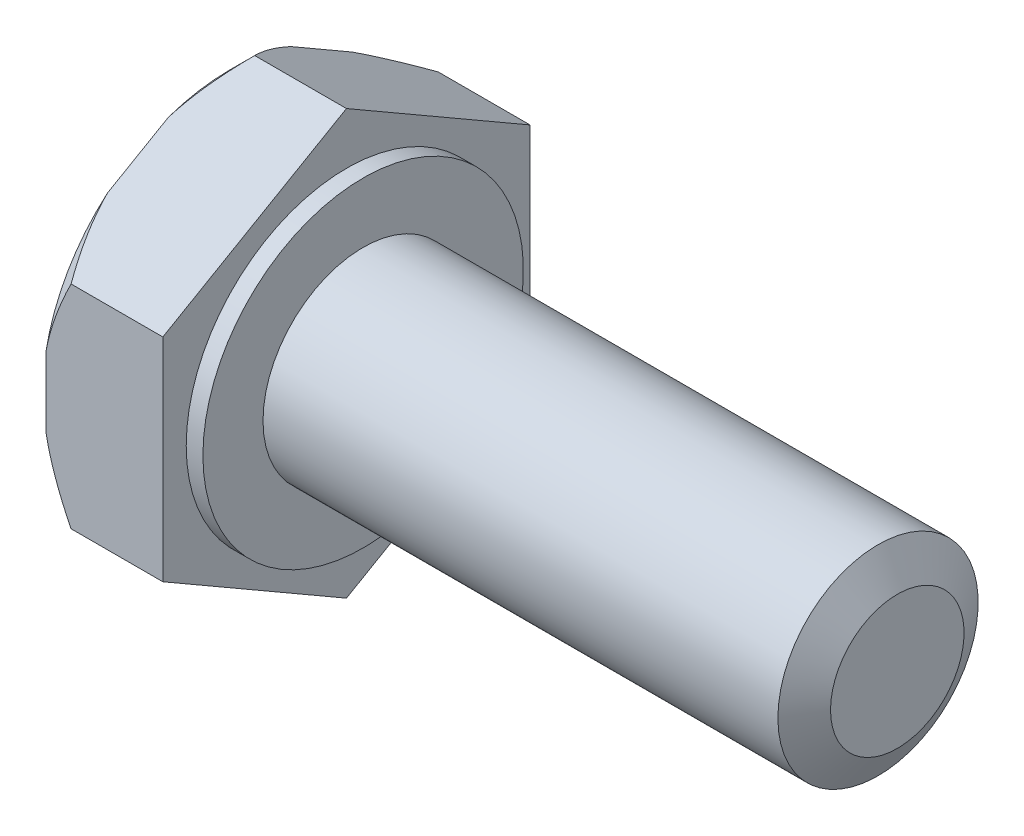
from build123d import *

# Parameters (mm, degrees)
SKETCH2_OUTSIDE_W  = 11.336
SKETCH2_OUTSIDE_H  = 11.336
CUT_EXTRUDE1_DEPTH = 10


with BuildPart() as part:
    # Sketch1 → Revolve1 (revolve)
    with BuildSketch(Plane.XY):
        Polygon((0, 1.5), (0, 2.4), (-0.25, 2.4), (-0.25, 3.3), (-1.5, 3.3), (-2, 2.8), (-2, 0), (8, 0), (8, 1), (7.711324865, 1.5), align=None)
    revolve(axis=Axis((-88.99, 0, 0), (1, 0, 0)))

    # Sketch2 outside → Cut-Extrude1 (cut)
    with BuildSketch(Plane(origin=(0, 0, 0), x_dir=(0, 0, -1), z_dir=(1, 0, 0))):
        Rectangle(SKETCH2_OUTSIDE_W, SKETCH2_OUTSIDE_H)
        Polygon((0, 3.175426481), (-2.75, 1.58771324), (-2.75, -1.58771324), (0, -3.175426481), (2.75, -1.58771324), (2.75, 1.58771324), align=None, mode=Mode.SUBTRACT)
    extrude(amount=-CUT_EXTRUDE1_DEPTH, mode=Mode.SUBTRACT)


solid = part.part
